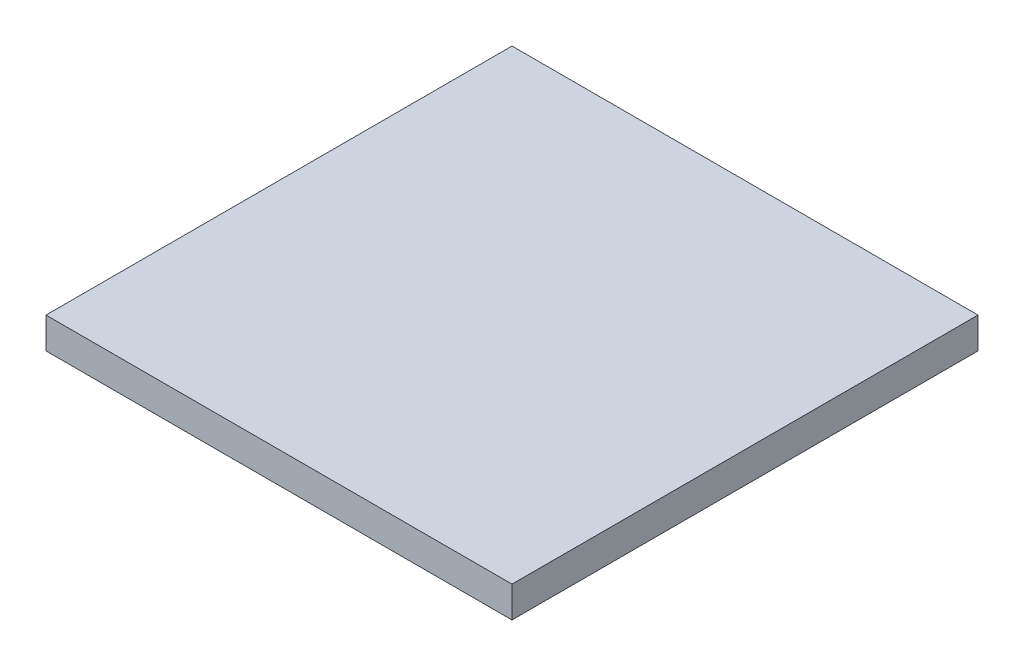
from build123d import *

# Parameters (mm, degrees)
SKETCH1_W           = 30
SKETCH1_H           = 30
BOSS_EXTRUDE1_DEPTH = 2


with BuildPart() as part:
    # Sketch1 → Boss-Extrude1 (new body)
    with BuildSketch(Plane(origin=(0, 0, 0), x_dir=(1, 0, 0), z_dir=(0, 1, 0))):
        Rectangle(SKETCH1_W, SKETCH1_H)
    extrude(amount=BOSS_EXTRUDE1_DEPTH)


solid = part.part
